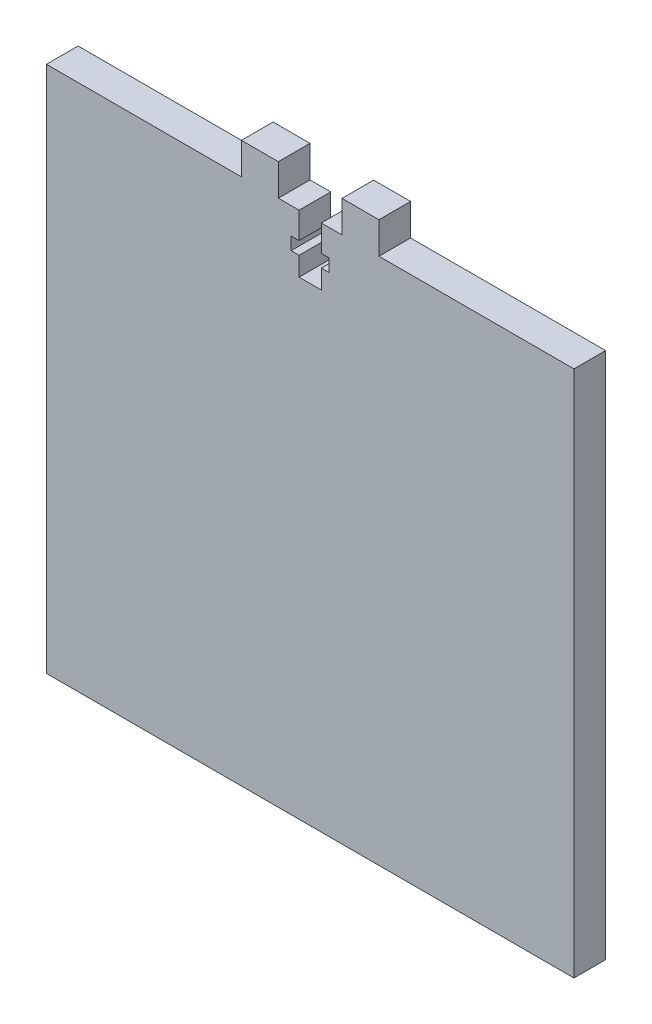
from build123d import *

# Parameters (mm, degrees)
SKETCH_1_W          = 100
SKETCH_1_H          = 100
EXTRUDE_1_DEPTH     = 6
SKETCH_2_W          = 7
SKETCH_2_H          = 6
EXTRUDE_2_DEPTH     = 6
CUT_EXTRUDE_1_DEPTH = 7


with BuildPart() as part:
    # Эскиз1 → Бобышка-Вытянуть1 (new body)
    with BuildSketch(Plane.XY):
        Rectangle(SKETCH_1_W, SKETCH_1_H)
    extrude(amount=EXTRUDE_1_DEPTH)

    # Эскиз2 → Бобышка-Вытянуть2 (add)
    with BuildSketch(Plane.XY.offset(6)):
        with Locations((-9.531849908, 53)):
            Rectangle(SKETCH_2_W, SKETCH_2_H)
        with Locations((9.531849908, 53)):
            Rectangle(SKETCH_2_W, SKETCH_2_H)
    extrude(amount=-EXTRUDE_2_DEPTH)

    # Эскиз3 → Вырез-Вытянуть1 (cut, through all)
    with BuildSketch(Plane.XY.offset(6)):
        Polygon((-2.1, 45), (-3.6, 45), (-3.6, 42.6), (-2.1, 42.6), (-2.1, 39), (2.1, 39), (2.1, 42.6), (3.6, 42.6), (3.6, 45), (2.1, 45), (2.1, 50), (-2.1, 50), align=None)
    extrude(amount=-CUT_EXTRUDE_1_DEPTH, mode=Mode.SUBTRACT)


solid = part.part
